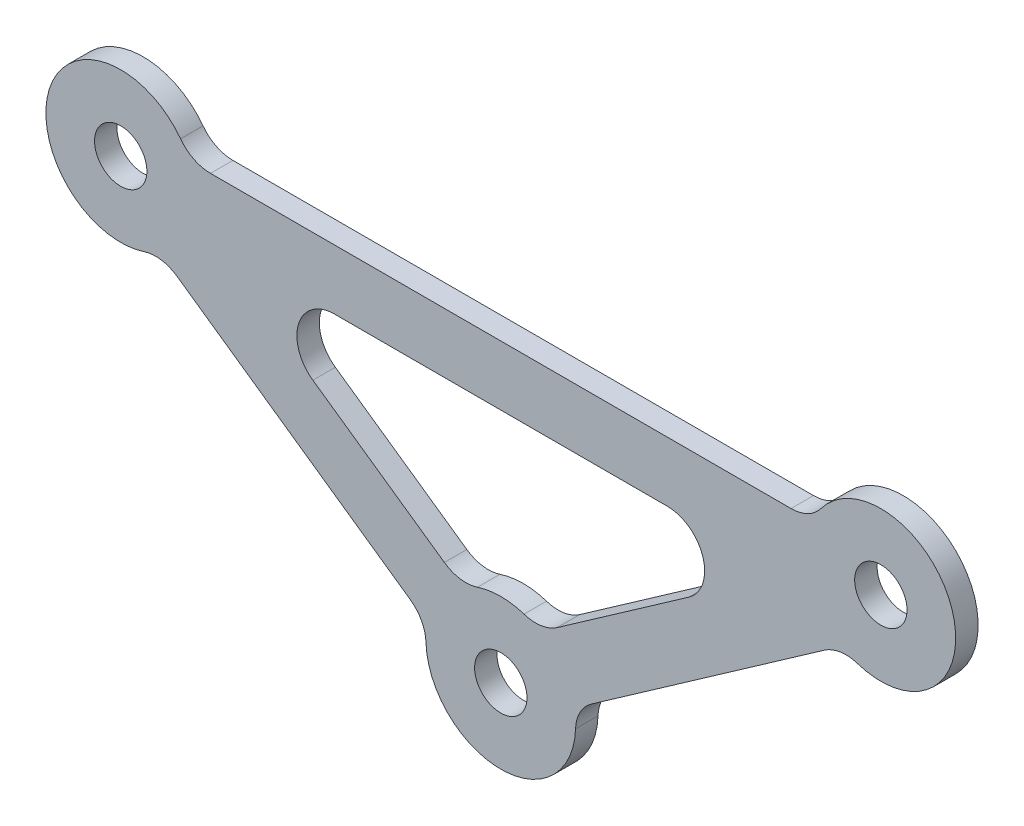
from build123d import *

# Parameters (mm, degrees)
SKETCH_1_R      = 3.5
EXTRUDE_2_DEPTH = 3


with BuildPart() as part:
    # 草圖1 → 填料-伸長2 (new body)
    with BuildSketch(Plane.XY):
        with BuildLine():
            Line((43.25190796, -10.159525413), (12.124130277, -31.955429995))
            ThreePointArc((12.124130277, -31.955429995), (10.595221, -33.670386808), (9.994674972, -35.888039829))
            ThreePointArc((9.994674972, -35.888039829), (0, -45.561739054), (-9.994674972, -35.888039829))
            ThreePointArc((-9.994674972, -35.888039829), (-10.595221, -33.670386808), (-12.124130277, -31.955429995))
            Line((-12.124130277, -31.955429995), (-43.25190796, -10.159525413))
            ThreePointArc((-43.25190796, -10.159525413), (-45.386357993, -9.309370423), (-47.67566901, -9.503523757))
            ThreePointArc((-47.67566901, -9.503523757), (-60.324596253, 3.007057995), (-42.787426746, 6))
            ThreePointArc((-42.787426746, 6), (-41.023494723, 4.527864045), (-38.787426746, 4))
            Line((-38.787426746, 4), (38.787426746, 4))
            ThreePointArc((38.787426746, 4), (41.023494723, 4.527864045), (42.787426746, 6))
            ThreePointArc((42.787426746, 6), (60.324596253, 3.007057995), (47.67566901, -9.503523757))
            ThreePointArc((47.67566901, -9.503523757), (45.386357993, -9.309370423), (43.25190796, -10.159525413))
        make_face()
        with Locations((50.787426746, 0)):
            Circle(SKETCH_1_R, mode=Mode.SUBTRACT)
        with Locations((-50.787426746, 0)):
            Circle(SKETCH_1_R, mode=Mode.SUBTRACT)
        with Locations((0, -35.561739054)):
            Circle(SKETCH_1_R, mode=Mode.SUBTRACT)
        with BuildLine():
            Line((-22.243073525, -4), (22.243073525, -4))
            ThreePointArc((22.243073525, -4), (27.011658278, -7.496471002), (25.110955706, -13.095760221))
            Line((25.110955706, -13.095760221), (7.535518786, -25.40221364))
            ThreePointArc((7.535518786, -25.40221364), (5.401068753, -26.252368631), (3.111757736, -26.058215297))
            ThreePointArc((3.111757736, -26.058215297), (0, -25.561739054), (-3.111757736, -26.058215297))
            ThreePointArc((-3.111757736, -26.058215297), (-5.401068753, -26.252368631), (-7.535518786, -25.40221364))
            Line((-7.535518786, -25.40221364), (-25.110955706, -13.095760221))
            ThreePointArc((-25.110955706, -13.095760221), (-27.011658278, -7.496471002), (-22.243073525, -4))
        make_face(mode=Mode.SUBTRACT)
    extrude(amount=EXTRUDE_2_DEPTH)


solid = part.part
